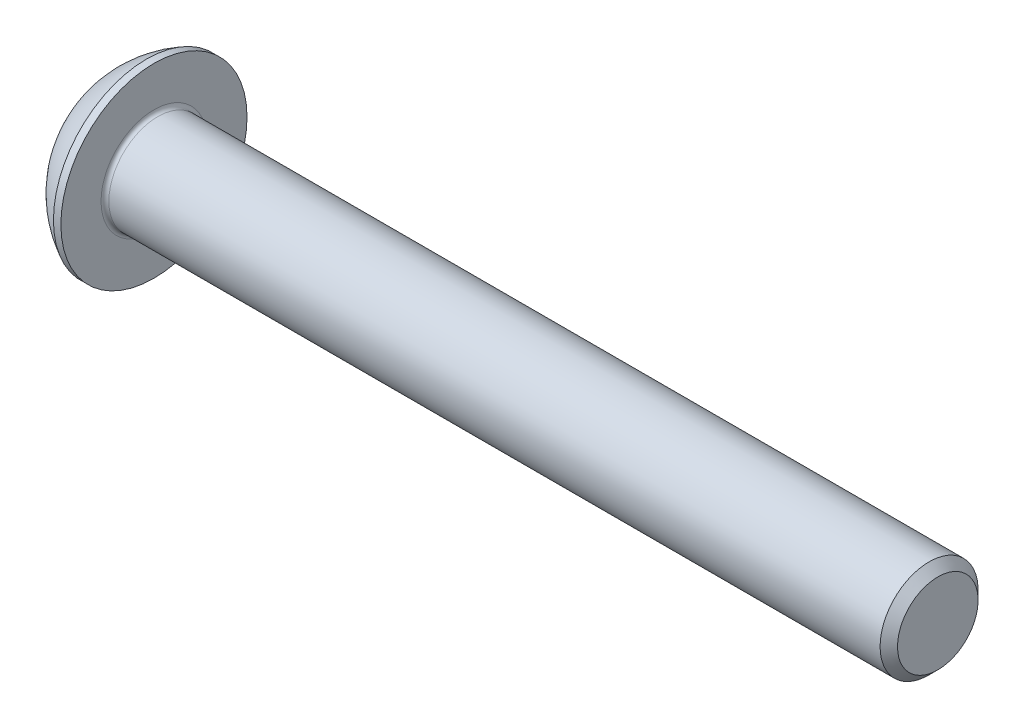
from build123d import *

# Parameters (mm, degrees)
FILLET1_R   = 0.2
HEX_2_DEPTH = 1.56


with BuildPart() as part:
    # BodySke → BaseBody (revolve)
    with BuildSketch(Plane.XY):
        with BuildLine():
            Line((42.75, 0), (42.75, 2.055))
            Line((42.75, 2.055), (42.305, 2.5))
            Line((42.305, 2.5), (2.75, 2.5))
            Line((2.75, 2.5), (2.75, 4.75))
            Line((2.75, 4.75), (2.37, 4.75))
            ThreePointArc((2.37, 4.75), (0.992680215, 3.754414901), (0, 2.375))
            Line((0, 2.375), (0, 0))
            Line((0, 0), (42.75, 0))
        make_face()
    revolve(axis=Axis((0, 0, 0), (1, 0, 0)))

    # Fillet1
    fillet1_edges = [part.edges().sort_by_distance(p)[0] for p in [
        (2.75, -2.5, 0),
    ]]
    fillet(fillet1_edges, radius=FILLET1_R)

    # Sketch2 → PreBroach (revolve, cut)
    with BuildSketch(Plane.XY):
        Polygon((0, 1.5), (1.56, 1.5), (2.426025404, 0), (0, 0), align=None)
    revolve(axis=Axis((0, 0, 0), (1, 0, 0)), mode=Mode.SUBTRACT)

    # Sketch3 → Hex 2 (cut)
    with BuildSketch(Plane(origin=(0, 0, 0), x_dir=(0, 0, -1), z_dir=(1, 0, 0))):
        Polygon((-1.5, -0.866025404), (-1.5, 0.866025404), (0, 1.732050808), (1.5, 0.866025404), (1.5, -0.866025404), (0, -1.732050808), align=None)
    extrude(amount=HEX_2_DEPTH, mode=Mode.SUBTRACT)


solid = part.part
